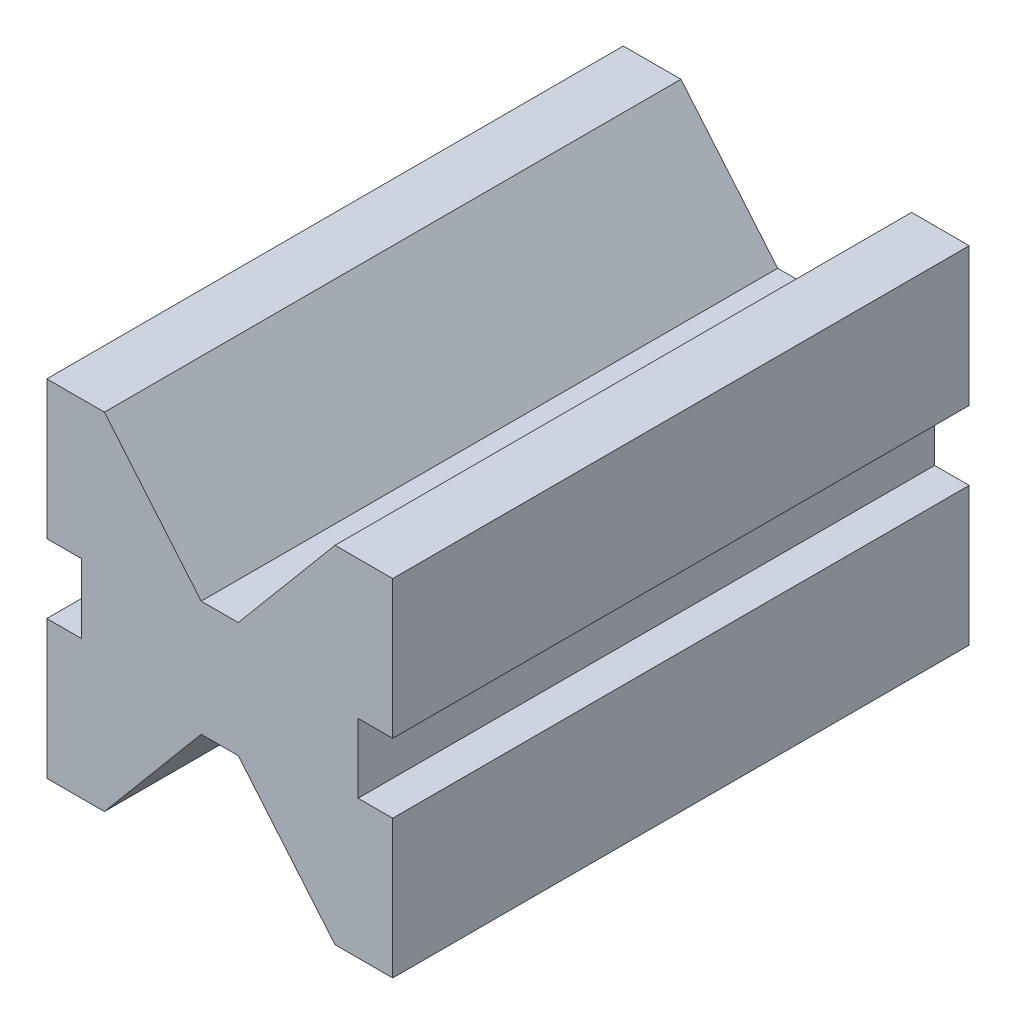
from build123d import *

# Parameters (mm, degrees)
SKETCH1_W           = 60
SKETCH1_H           = 60
BOSS_EXTRUDE1_DEPTH = 100
SKETCH3_W           = 6
SKETCH3_H           = 12
CUT_EXTRUDE2_DEPTH  = 101


with BuildPart() as part:
    # Sketch1 → Boss-Extrude1 (new body)
    with BuildSketch(Plane.XY):
        with Locations((30, 30)):
            Rectangle(SKETCH1_W, SKETCH1_H)
    extrude(amount=-BOSS_EXTRUDE1_DEPTH)

    # Sketch3 → Cut-Extrude2 (cut, through all)
    with BuildSketch(Plane.XY):
        Polygon((26.781992624, 20), (33.218007376, 20), (50, 0), (10, 0), align=None)
        Polygon((26.781992624, 40), (33.218007376, 40), (50, 60), (10, 60), align=None)
        with Locations((57, 30)):
            Rectangle(SKETCH3_W, SKETCH3_H)
        with Locations((3, 30)):
            Rectangle(SKETCH3_W, SKETCH3_H)
    extrude(amount=-CUT_EXTRUDE2_DEPTH, mode=Mode.SUBTRACT)


solid = part.part
